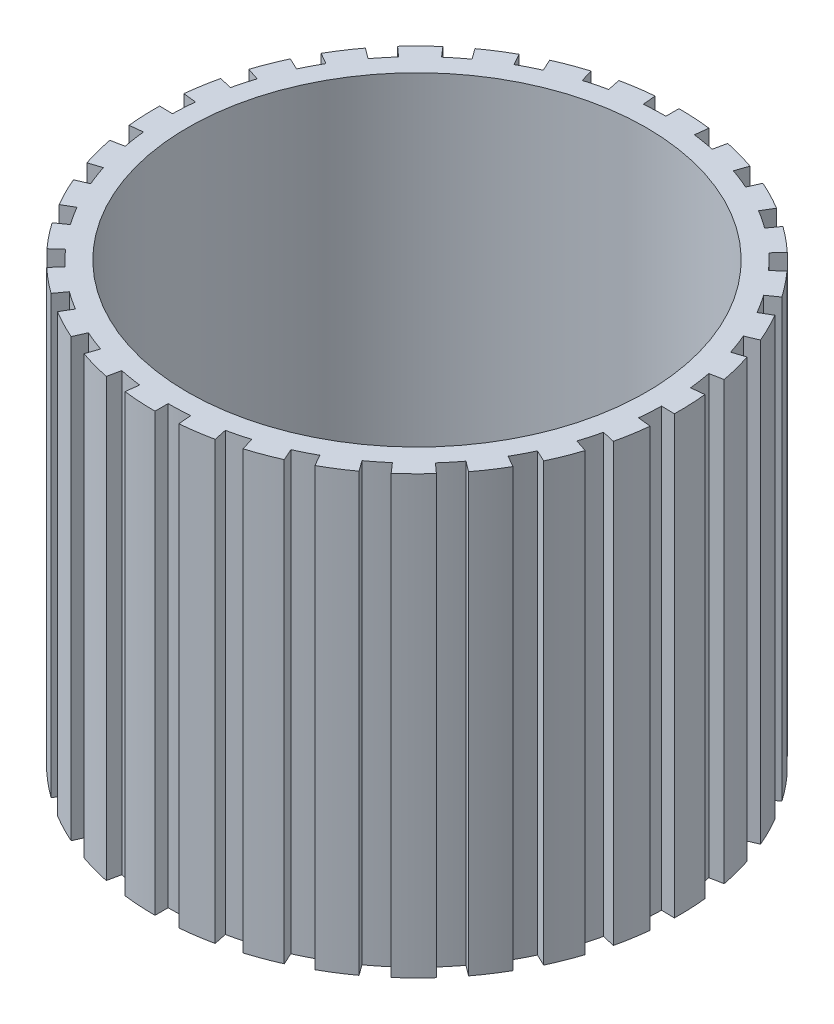
from build123d import *

# Parameters (mm, degrees)
SKETCH1_R           = 52.5
BOSS_EXTRUDE1_DEPTH = 100


with BuildPart() as part:
    # Sketch1 → Boss-Extrude1 (new body)
    with BuildSketch(Plane(origin=(0, 0, 0), x_dir=(1, 0, 0), z_dir=(0, 1, 0))):
        with BuildLine():
            Line((0, 57), (0, 60))
            ThreePointArc((0, 60), (3.662912372, 59.888087905), (7.312160604, 59.552769098))
            Line((7.312160604, 59.552769098), (6.946552574, 56.575130644))
            ThreePointArc((6.946552574, 56.575130644), (9.407713534, 56.218279288), (11.850966377, 55.754413242))
            Line((11.850966377, 55.754413242), (12.474701449, 58.688856044))
            ThreePointArc((12.474701449, 58.688856044), (16.034302565, 57.817827193), (19.534089267, 56.731114536))
            Line((19.534089267, 56.731114536), (18.557384804, 53.894558809))
            ThreePointArc((18.557384804, 53.894558809), (20.890569923, 53.033801375), (23.183988655, 52.072091086))
            Line((23.183988655, 52.072091086), (24.404198585, 54.812727459))
            ThreePointArc((24.404198585, 54.812727459), (27.704916794, 53.220649991), (30.902284495, 51.430038042))
            Line((30.902284495, 51.430038042), (29.35717027, 48.85853614))
            ThreePointArc((29.35717027, 48.85853614), (31.460408163, 47.531491858), (33.503759381, 46.113968679))
            Line((33.503759381, 46.113968679), (35.267115138, 48.541019662))
            ThreePointArc((35.267115138, 48.541019662), (38.164693217, 46.297475003), (40.919901604, 43.881222097))
            Line((40.919901604, 43.881222097), (38.873906524, 41.687160992))
            ThreePointArc((38.873906524, 41.687160992), (40.655275602, 39.951828065), (42.359255052, 38.140444562))
            Line((42.359255052, 38.140444562), (44.588689529, 40.147836382))
            ThreePointArc((44.588689529, 40.147836382), (46.956489411, 37.350878198), (49.149122657, 34.414586181))
            Line((49.149122657, 34.414586181), (46.691666524, 32.693856872))
            ThreePointArc((46.691666524, 32.693856872), (48.073312411, 30.626077676), (49.363448016, 28.5))
            Line((49.363448016, 28.5), (51.961524227, 30))
            ThreePointArc((51.961524227, 30), (53.696061696, 26.771868787), (55.230291207, 23.443867709))
            Line((55.230291207, 23.443867709), (52.468776647, 22.271674324))
            ThreePointArc((52.468776647, 22.271674324), (53.390314787, 19.961820732), (54.210221429, 17.613968679))
            Line((54.210221429, 17.613968679), (57.063390978, 18.541019662))
            ThreePointArc((57.063390978, 18.541019662), (58.088858423, 15.022800243), (58.897631007, 11.448539723))
            Line((58.897631007, 11.448539723), (55.952749457, 10.876112736))
            ThreePointArc((55.952749457, 10.876112736), (56.373904212, 8.425136434), (56.687748036, 5.958122406))
            Line((56.687748036, 5.958122406), (59.671313722, 6.271707796))
            ThreePointArc((59.671313722, 6.271707796), (59.942893295, 2.617163242), (59.990861709, -1.047144386))
            Line((59.990861709, -1.047144386), (56.991318624, -0.994787167))
            ThreePointArc((56.991318624, -0.994787167), (56.89368351, -3.479766753), (56.687748036, -5.958122406))
            Line((56.687748036, -5.958122406), (59.671313722, -6.271707796))
            ThreePointArc((59.671313722, -6.271707796), (59.177136092, -9.902856352), (58.462203887, -13.497063261))
            Line((58.462203887, -13.497063261), (55.539093693, -12.822210098))
            ThreePointArc((55.539093693, -12.822210098), (54.926935833, -15.232587436), (54.210221429, -17.613968679))
            Line((54.210221429, -17.613968679), (57.063390978, -18.541019662))
            ThreePointArc((57.063390978, -18.541019662), (55.825054079, -21.990073603), (54.378467222, -25.357095704))
            Line((54.378467222, -25.357095704), (51.659543861, -24.089240919))
            ThreePointArc((51.659543861, -24.089240919), (50.559617491, -26.319670954), (49.363448016, -28.5))
            Line((49.363448016, -28.5), (51.961524227, -30))
            ThreePointArc((51.961524227, -30), (50.033149324, -33.116219119), (47.918130603, -36.108901389))
            Line((47.918130603, -36.108901389), (45.522224073, -34.30345632))
            ThreePointArc((45.522224073, -34.30345632), (43.982601253, -36.256458556), (42.359255052, -38.140444562))
            Line((42.359255052, -38.140444562), (44.588689529, -40.147836382))
            ThreePointArc((44.588689529, -40.147836382), (42.054555858, -42.795026949), (39.363541739, -45.282574813))
            Line((39.363541739, -45.282574813), (37.395364652, -43.018446073))
            ThreePointArc((37.395364652, -43.018446073), (35.483334288, -44.608664941), (33.503759381, -46.113968679))
            Line((33.503759381, -46.113968679), (35.267115138, -48.541019662))
            ThreePointArc((35.267115138, -48.541019662), (32.237976501, -50.603486749), (29.088577215, -52.477182428))
            Line((29.088577215, -52.477182428), (27.634148354, -49.853323307))
            ThreePointArc((27.634148354, -49.853323307), (25.433275347, -51.011258611), (23.183988655, -52.072091086))
            Line((23.183988655, -52.072091086), (24.404198585, -54.812727459))
            ThreePointArc((24.404198585, -54.812727459), (21.012442876, -56.200331355), (17.542302283, -57.378285358))
            Line((17.542302283, -57.378285358), (16.665187169, -54.50937109))
            ThreePointArc((16.665187169, -54.50937109), (14.271660231, -55.184415502), (11.850966377, -55.754413242))
            Line((11.850966377, -55.754413242), (12.474701449, -58.688856044))
            ThreePointArc((12.474701449, -58.688856044), (8.868564668, -59.340951802), (5.229344565, -59.771681886))
            Line((5.229344565, -59.771681886), (4.967877337, -56.783097791))
            ThreePointArc((4.967877337, -56.783097791), (2.48630508, -56.94574863), (0, -57))
            Line((0, -57), (0, -60))
            ThreePointArc((0, -60), (-3.662912372, -59.888087905), (-7.312160604, -59.552769098))
            Line((-7.312160604, -59.552769098), (-6.946552574, -56.575130644))
            ThreePointArc((-6.946552574, -56.575130644), (-9.407713534, -56.218279288), (-11.850966377, -55.754413242))
            Line((-11.850966377, -55.754413242), (-12.474701449, -58.688856044))
            ThreePointArc((-12.474701449, -58.688856044), (-16.034302565, -57.817827193), (-19.534089267, -56.731114536))
            Line((-19.534089267, -56.731114536), (-18.557384804, -53.894558809))
            ThreePointArc((-18.557384804, -53.894558809), (-20.890569923, -53.033801375), (-23.183988655, -52.072091086))
            Line((-23.183988655, -52.072091086), (-24.404198585, -54.812727459))
            ThreePointArc((-24.404198585, -54.812727459), (-27.704916794, -53.220649991), (-30.902284495, -51.430038042))
            Line((-30.902284495, -51.430038042), (-29.35717027, -48.85853614))
            ThreePointArc((-29.35717027, -48.85853614), (-31.460408163, -47.531491858), (-33.503759381, -46.113968679))
            Line((-33.503759381, -46.113968679), (-35.267115138, -48.541019662))
            ThreePointArc((-35.267115138, -48.541019662), (-38.164693217, -46.297475003), (-40.919901604, -43.881222097))
            Line((-40.919901604, -43.881222097), (-38.873906524, -41.687160992))
            ThreePointArc((-38.873906524, -41.687160992), (-40.655275602, -39.951828065), (-42.359255052, -38.140444562))
            Line((-42.359255052, -38.140444562), (-44.588689529, -40.147836382))
            ThreePointArc((-44.588689529, -40.147836382), (-46.956489411, -37.350878198), (-49.149122657, -34.414586181))
            Line((-49.149122657, -34.414586181), (-46.691666524, -32.693856872))
            ThreePointArc((-46.691666524, -32.693856872), (-48.073312411, -30.626077676), (-49.363448016, -28.5))
            Line((-49.363448016, -28.5), (-51.961524227, -30))
            ThreePointArc((-51.961524227, -30), (-53.696061696, -26.771868787), (-55.230291207, -23.443867709))
            Line((-55.230291207, -23.443867709), (-52.468776647, -22.271674324))
            ThreePointArc((-52.468776647, -22.271674324), (-53.390314787, -19.961820732), (-54.210221429, -17.613968679))
            Line((-54.210221429, -17.613968679), (-57.063390978, -18.541019662))
            ThreePointArc((-57.063390978, -18.541019662), (-58.088858423, -15.022800243), (-58.897631007, -11.448539723))
            Line((-58.897631007, -11.448539723), (-55.952749457, -10.876112736))
            ThreePointArc((-55.952749457, -10.876112736), (-56.373904212, -8.425136434), (-56.687748036, -5.958122406))
            Line((-56.687748036, -5.958122406), (-59.671313722, -6.271707796))
            ThreePointArc((-59.671313722, -6.271707796), (-59.942893295, -2.617163242), (-59.990861709, 1.047144386))
            Line((-59.990861709, 1.047144386), (-56.991318624, 0.994787167))
            ThreePointArc((-56.991318624, 0.994787167), (-56.89368351, 3.479766753), (-56.687748036, 5.958122406))
            Line((-56.687748036, 5.958122406), (-59.671313722, 6.271707796))
            ThreePointArc((-59.671313722, 6.271707796), (-59.177136092, 9.902856352), (-58.462203887, 13.497063261))
            Line((-58.462203887, 13.497063261), (-55.539093693, 12.822210098))
            ThreePointArc((-55.539093693, 12.822210098), (-54.926935833, 15.232587436), (-54.210221429, 17.613968679))
            Line((-54.210221429, 17.613968679), (-57.063390978, 18.541019662))
            ThreePointArc((-57.063390978, 18.541019662), (-55.825054079, 21.990073603), (-54.378467222, 25.357095704))
            Line((-54.378467222, 25.357095704), (-51.659543861, 24.089240919))
            ThreePointArc((-51.659543861, 24.089240919), (-50.559617491, 26.319670954), (-49.363448016, 28.5))
            Line((-49.363448016, 28.5), (-51.961524227, 30))
            ThreePointArc((-51.961524227, 30), (-50.033149324, 33.116219119), (-47.918130603, 36.108901389))
            Line((-47.918130603, 36.108901389), (-45.522224073, 34.30345632))
            ThreePointArc((-45.522224073, 34.30345632), (-43.982601253, 36.256458556), (-42.359255052, 38.140444562))
            Line((-42.359255052, 38.140444562), (-44.588689529, 40.147836382))
            ThreePointArc((-44.588689529, 40.147836382), (-42.054555858, 42.795026949), (-39.363541739, 45.282574813))
            Line((-39.363541739, 45.282574813), (-37.395364652, 43.018446073))
            ThreePointArc((-37.395364652, 43.018446073), (-35.483334288, 44.608664941), (-33.503759381, 46.113968679))
            Line((-33.503759381, 46.113968679), (-35.267115138, 48.541019662))
            ThreePointArc((-35.267115138, 48.541019662), (-32.237976501, 50.603486749), (-29.088577215, 52.477182428))
            Line((-29.088577215, 52.477182428), (-27.634148354, 49.853323307))
            ThreePointArc((-27.634148354, 49.853323307), (-25.433275347, 51.011258611), (-23.183988655, 52.072091086))
            Line((-23.183988655, 52.072091086), (-24.404198585, 54.812727459))
            ThreePointArc((-24.404198585, 54.812727459), (-21.012442876, 56.200331355), (-17.542302283, 57.378285358))
            Line((-17.542302283, 57.378285358), (-16.665187169, 54.50937109))
            ThreePointArc((-16.665187169, 54.50937109), (-14.271660231, 55.184415502), (-11.850966377, 55.754413242))
            Line((-11.850966377, 55.754413242), (-12.474701449, 58.688856044))
            ThreePointArc((-12.474701449, 58.688856044), (-8.868564668, 59.340951802), (-5.229344565, 59.771681886))
            Line((-5.229344565, 59.771681886), (-4.967877337, 56.783097791))
            ThreePointArc((-4.967877337, 56.783097791), (-2.48630508, 56.94574863), (0, 57))
        make_face()
        Circle(SKETCH1_R, mode=Mode.SUBTRACT)
    extrude(amount=BOSS_EXTRUDE1_DEPTH)


solid = part.part
